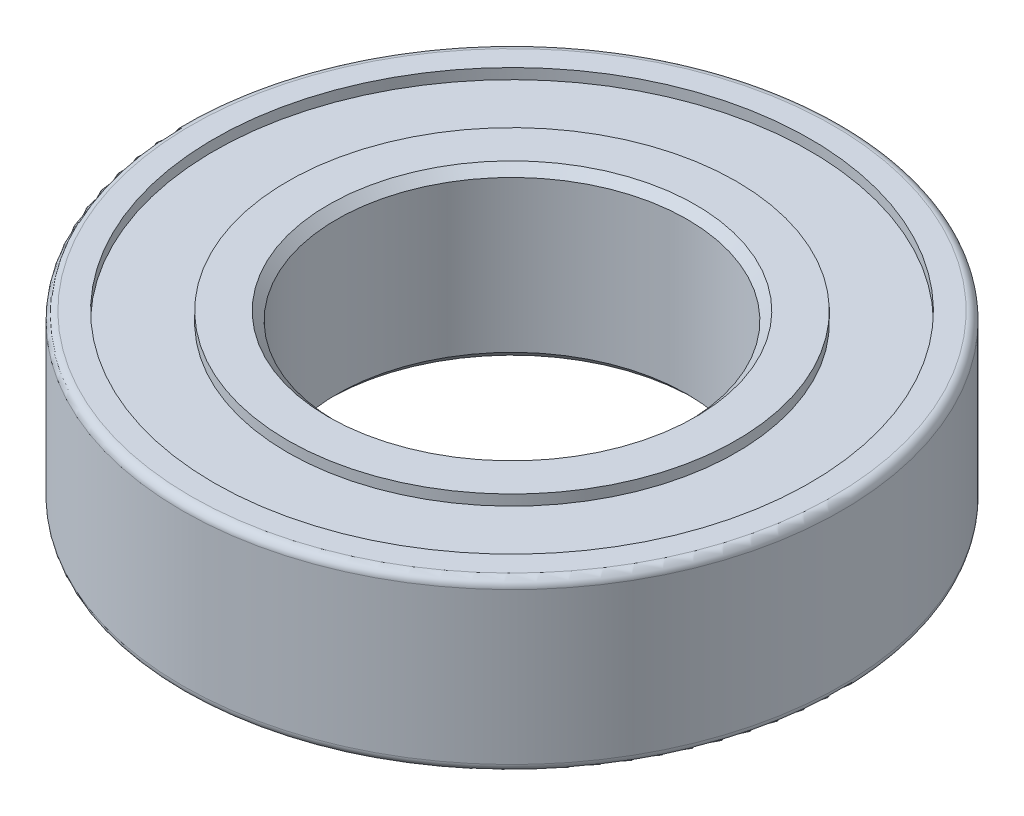
from build123d import *


with BuildPart() as part:
    # Sketch1 → Revolve1 (revolve)
    with BuildSketch(Plane(origin=(0, 0, 0), x_dir=(0, 0, -1), z_dir=(1, 0, 0))):
        with BuildLine():
            Line((-13.1, 6), (-12.5, 5.4))
            Line((-12.5, 5.4), (-12.5, -5.4))
            Line((-12.5, -5.4), (-13.1, -6))
            Line((-13.1, -6), (-16, -6))
            Line((-16, -6), (-16, -5.25))
            Line((-16, -5.25), (-21.25, -5.25))
            Line((-21.25, -5.25), (-21.25, -6))
            Line((-21.25, -6), (-22.9, -6))
            ThreePointArc((-22.9, -6), (-23.324264069, -5.824264069), (-23.5, -5.4))
            Line((-23.5, -5.4), (-23.5, 5.4))
            ThreePointArc((-23.5, 5.4), (-23.324264069, 5.824264069), (-22.9, 6))
            Line((-22.9, 6), (-21.25, 6))
            Line((-21.25, 6), (-21.25, 5.25))
            Line((-21.25, 5.25), (-16, 5.25))
            Line((-16, 5.25), (-16, 6))
            Line((-16, 6), (-13.1, 6))
        make_face()
    revolve(axis=Axis((0, 26.680665717, 0), (0, -1, 0)))


solid = part.part
